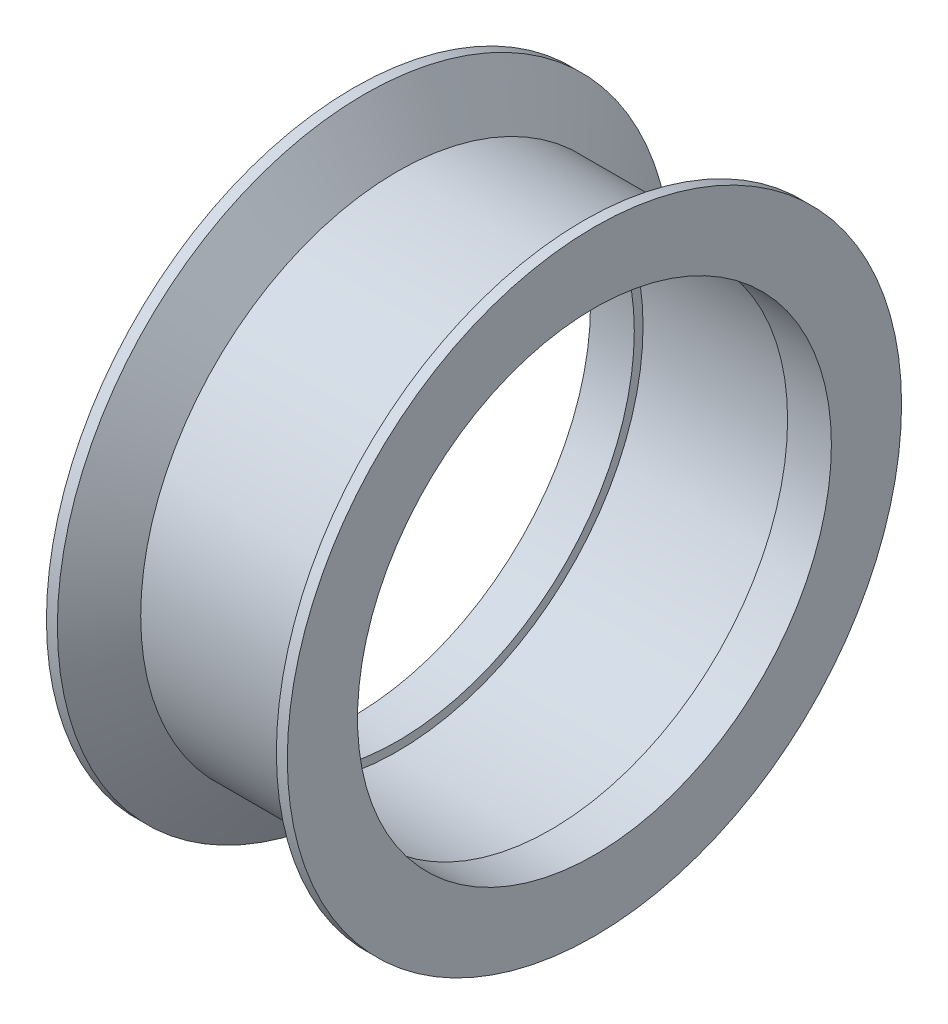
from build123d import *


with BuildPart() as part:
    # Sketch1 → Revolve1 (revolve)
    with BuildSketch(Plane.XY):
        Polygon((-3.5, 11.72), (-5, 14.024886114), (-5.5, 14.024886114), (-5.5, 10.82), (-3.5, 10.82), (-3.5, 11.22), (3.5, 11.22), (3.5, 10.82), (5.5, 10.82), (5.5, 14.024886114), (5, 14.024886114), (3.5, 11.72), align=None)
    revolve(axis=Axis((0, 0, 0), (-1, 0, 0)))


solid = part.part
